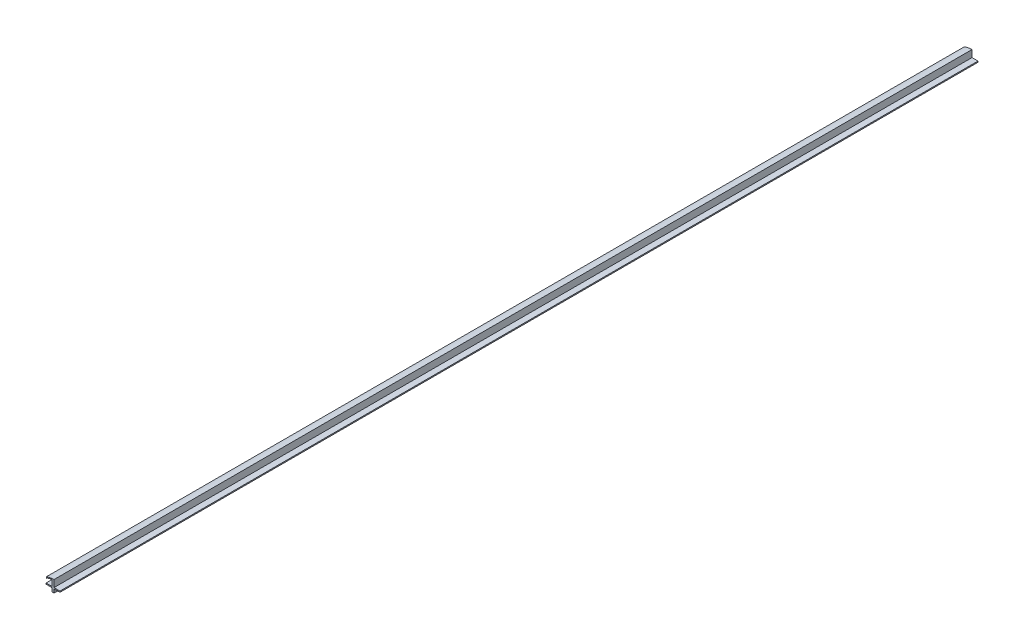
from build123d import *

# Parameters (mm, degrees)
EXTRUDE1_DEPTH = 533.4


with BuildPart() as part:
    # Sketch1 → Extrude1 (new body, symmetric)
    with BuildSketch(Plane.XY):
        with BuildLine():
            Line((1169.5811, 22.86), (1169.5811, 18.542))
            Line((1169.5811, 18.542), (1167.2189, 18.542))
            Line((1167.2189, 18.542), (1167.2189, 22.86))
            Line((1167.2189, 22.86), (1160.272, 22.86))
            Line((1160.272, 22.86), (1160.272, 24.13))
            Line((1160.272, 24.13), (1167.2189, 24.13))
            Line((1167.2189, 24.13), (1167.2189, 30.988))
            ThreePointArc((1167.2189, 30.988), (1163.937883426, 30.530285143), (1160.907403243, 29.192091395))
            Line((1160.907403243, 29.192091395), (1160.483801081, 30.389363798))
            ThreePointArc((1160.483801081, 30.389363798), (1164.93748479, 31.786014706), (1169.5811, 32.258))
            Line((1169.5811, 32.258), (1169.5811, 24.13))
            Line((1169.5811, 24.13), (1176.528, 24.13))
            Line((1176.528, 24.13), (1176.528, 22.86))
            Line((1176.528, 22.86), (1169.5811, 22.86))
        make_face()
    extrude(amount=EXTRUDE1_DEPTH, both=True)


solid = part.part
